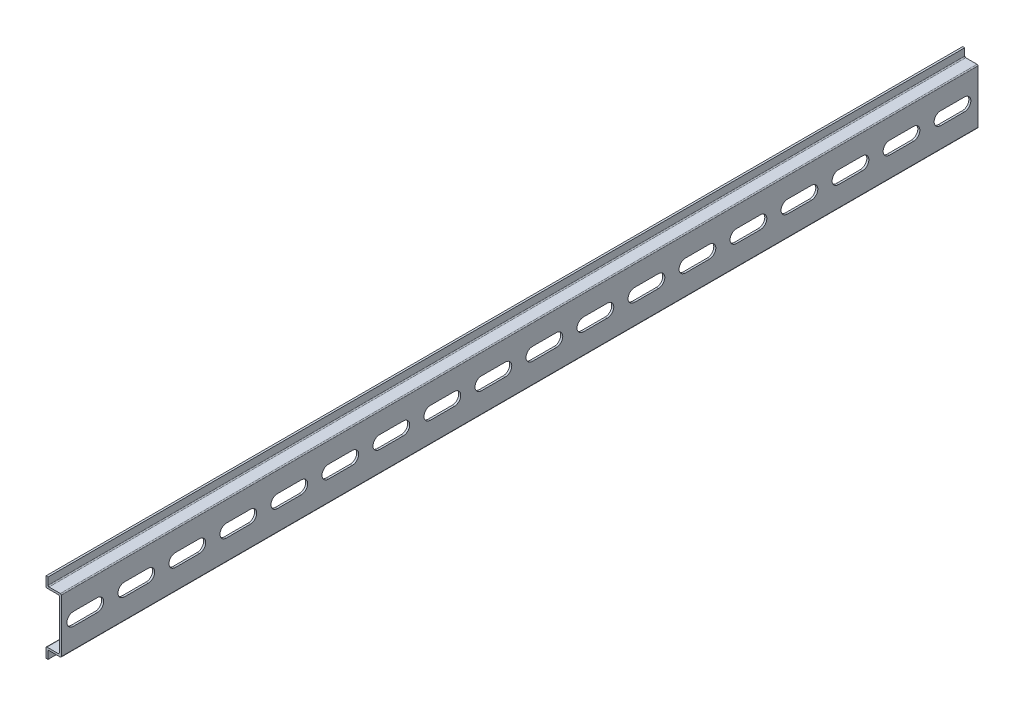
from build123d import *

# Parameters (mm, degrees)
EXTRUDE_THIN1_DEPTH = 449.2625
CUT_EXTRUDE1_START  = -8.5
CUT_EXTRUDE1_DEPTH  = 9.5
LPATTERN1_COUNT     = 18
LPATTERN1_PITCH     = 25
FILLET1_R           = 0.5


with BuildPart() as part:
    # Sketch3 → Extrude-Thin1 (new body)
    with BuildSketch(Plane.XY):
        Polygon((-6.5, 17.5), (-6.5, 13.5), (0, 13.5), (0, -13.5), (-6.5, -13.5), (-6.5, -17.5), (-7.5, -17.5), (-7.5, -12.5), (-1, -12.5), (-1, 12.5), (-7.5, 12.5), (-7.5, 17.5), align=None)
    extrude(amount=EXTRUDE_THIN1_DEPTH)

    # Sketch4 → Cut-Extrude1 (cut)
    with BuildSketch(Plane(origin=(0, 0, 0), x_dir=(0, 0, -1), z_dir=(1, 0, 0)).offset(CUT_EXTRUDE1_START)):
        with BuildLine():
            Line((-6.65, -3.15), (-18.35, -3.15))
            ThreePointArc((-18.35, -3.15), (-21.5, 0), (-18.35, 3.15))
            Line((-18.35, 3.15), (-6.65, 3.15))
            ThreePointArc((-6.65, 3.15), (-3.5, 0), (-6.65, -3.15))
        make_face()
    cut_extrude1 = extrude(amount=CUT_EXTRUDE1_DEPTH, mode=Mode.SUBTRACT)

    # LPattern1: Cut-Extrude1 ×18
    with Locations(*[(0, 0, i * LPATTERN1_PITCH) for i in range(1, LPATTERN1_COUNT)]):
        add(cut_extrude1, mode=Mode.SUBTRACT)

    # Fillet1
    fillet1_edges = [part.edges().sort_by_distance(p)[0] for p in [
        (-6.5, 13.5, 224.63125),
        (0, 13.5, 224.63125),
        (0, -13.5, 224.63125),
        (-6.5, -13.5, 224.63125),
        (-7.5, -12.5, 224.63125),
        (-1, -12.5, 224.63125),
        (-1, 12.5, 224.63125),
        (-7.5, 12.5, 224.63125),
    ]]
    fillet(fillet1_edges, radius=FILLET1_R)


solid = part.part
